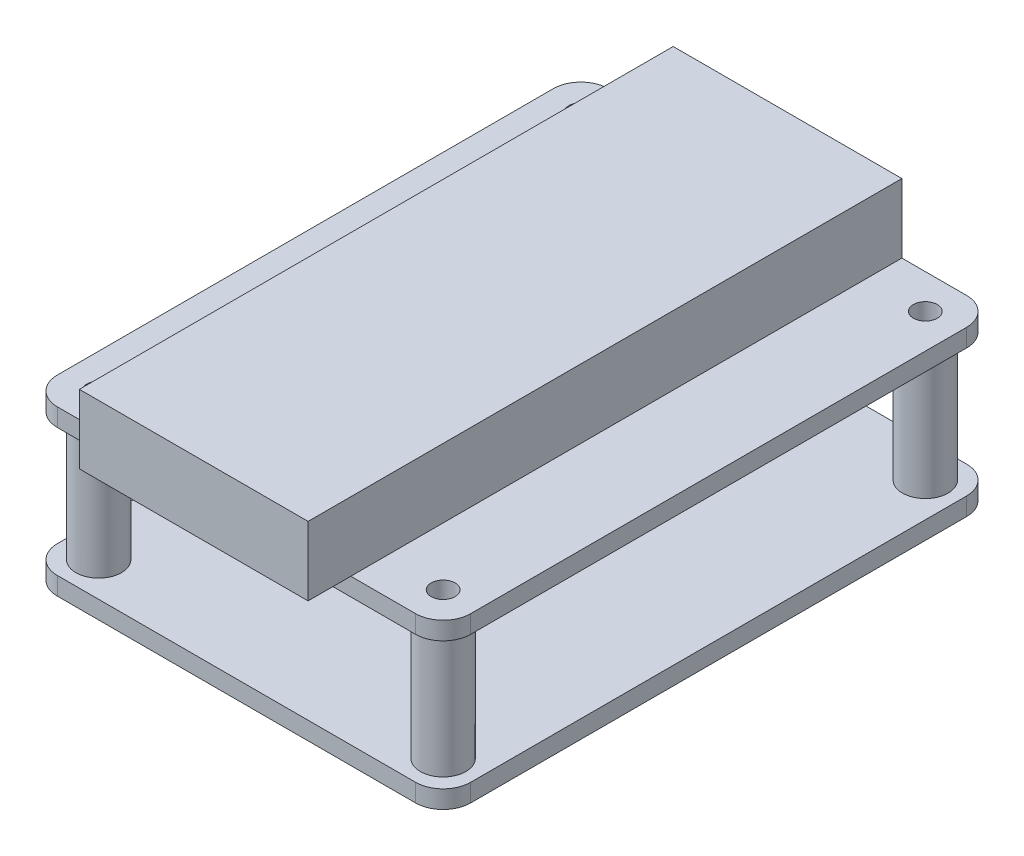
from build123d import *

# Parameters (mm, degrees)
SKETCH1_R           = 1.1
BOSS_EXTRUDE1_DEPTH = 1.651
SKETCH2_R           = 1.1
BOSS_EXTRUDE2_DEPTH = 1.651
SKETCH3_R           = 2.1
SKETCH3_R_2         = 1.1
BOSS_EXTRUDE3_DEPTH = 11.811
SKETCH4_W           = 21.082
SKETCH4_H           = 54.737
BOSS_EXTRUDE4_DEPTH = 6.35


with BuildPart() as part:
    # Sketch1 → Boss-Extrude1 (new body)
    with BuildSketch(Plane(origin=(0, 0, 0), x_dir=(1, 0, 0), z_dir=(0, 1, 0))):
        with BuildLine():
            Line((-0.635, -3.175), (32.385, -3.175))
            ThreePointArc((32.385, -3.175), (34.181051224, -2.431051224), (34.925, -0.635))
            Line((34.925, -0.635), (34.925, 45.085))
            ThreePointArc((34.925, 45.085), (34.181051224, 46.881051224), (32.385, 47.625))
            Line((32.385, 47.625), (-0.635, 47.625))
            ThreePointArc((-0.635, 47.625), (-2.431051224, 46.881051224), (-3.175, 45.085))
            Line((-3.175, 45.085), (-3.175, -0.635))
            ThreePointArc((-3.175, -0.635), (-2.431051224, -2.431051224), (-0.635, -3.175))
        make_face()
        with Locations((0, 44.45)):
            Circle(SKETCH1_R, mode=Mode.SUBTRACT)
        with Locations((31.75, 44.45)):
            Circle(SKETCH1_R, mode=Mode.SUBTRACT)
        with Locations((31.75, 0)):
            Circle(SKETCH1_R, mode=Mode.SUBTRACT)
        Circle(SKETCH1_R, mode=Mode.SUBTRACT)
    extrude(amount=BOSS_EXTRUDE1_DEPTH)



with BuildPart() as body_2:
    # Sketch2 → Boss-Extrude2 (new body)
    with BuildSketch(Plane(origin=(0, 15.113, 0), x_dir=(-1, 0, 0), z_dir=(0, -1, 0))):
        with BuildLine():
            Line((3.175, -0.635), (3.175, 45.085))
            ThreePointArc((3.175, 45.085), (2.431051224, 46.881051224), (0.635, 47.625))
            Line((0.635, 47.625), (-32.385, 47.625))
            ThreePointArc((-32.385, 47.625), (-34.181051224, 46.881051224), (-34.925, 45.085))
            Line((-34.925, 45.085), (-34.925, -0.635))
            ThreePointArc((-34.925, -0.635), (-34.181051224, -2.431051224), (-32.385, -3.175))
            Line((-32.385, -3.175), (0.635, -3.175))
            ThreePointArc((0.635, -3.175), (2.431051224, -2.431051224), (3.175, -0.635))
        make_face()
        with Locations((-31.75, 44.45)):
            Circle(SKETCH2_R, mode=Mode.SUBTRACT)
        with Locations((0, 44.45)):
            Circle(SKETCH2_R, mode=Mode.SUBTRACT)
        with Locations((-31.75, 0)):
            Circle(SKETCH2_R, mode=Mode.SUBTRACT)
        Circle(SKETCH2_R, mode=Mode.SUBTRACT)
    extrude(amount=BOSS_EXTRUDE2_DEPTH)


with BuildPart() as part_1:
    add(part.part)

    add(body_2.part)  # Boss-Extrude3 merges body 2
    # Sketch3 → Boss-Extrude3 (add)
    with BuildSketch(Plane(origin=(0, 1.651, 0), x_dir=(1, 0, 0), z_dir=(0, 1, 0))):
        Circle(SKETCH3_R)
        Circle(SKETCH3_R_2, mode=Mode.SUBTRACT)
        with Locations((31.75, 0)):
            Circle(SKETCH3_R)
        with Locations((31.75, 0)):
            Circle(SKETCH3_R_2, mode=Mode.SUBTRACT)
        with Locations((31.75, 44.45)):
            Circle(SKETCH3_R)
        with Locations((31.75, 44.45)):
            Circle(SKETCH3_R_2, mode=Mode.SUBTRACT)
        with Locations((0, 44.45)):
            Circle(SKETCH3_R)
        with Locations((0, 44.45)):
            Circle(SKETCH3_R_2, mode=Mode.SUBTRACT)
    extrude(amount=BOSS_EXTRUDE3_DEPTH)

    # Sketch4 → Boss-Extrude4 (add)
    with BuildSketch(Plane(origin=(0, 15.113, 0), x_dir=(1, 0, 0), z_dir=(0, 1, 0))):
        with Locations((15.875, 20.2565)):
            Rectangle(SKETCH4_W, SKETCH4_H)
    extrude(amount=BOSS_EXTRUDE4_DEPTH)


solid = part_1.part
